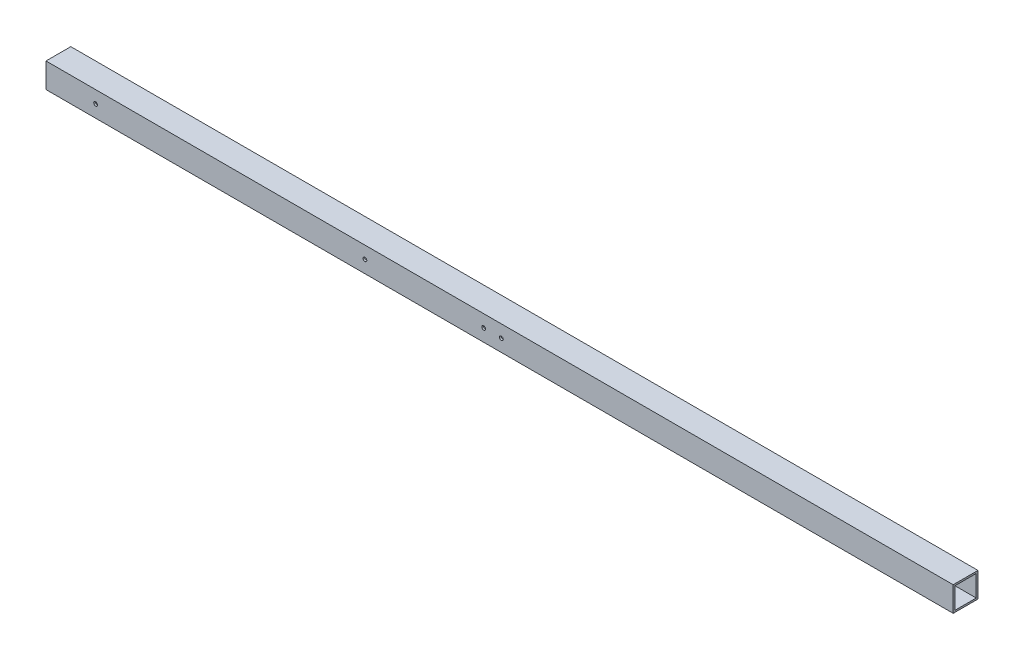
from build123d import *

# Parameters (mm, degrees)
SKETCH1_W           = 44.45
SKETCH1_H           = 44.45
SKETCH1_W_2         = 38.1
SKETCH1_H_2         = 38.1
BOSS_EXTRUDE1_DEPTH = 1625.6
SKETCH2_R           = 3.3734375
CUT_EXTRUDE1_DEPTH  = 45.45


with BuildPart() as part:
    # Sketch1 → Boss-Extrude1 (new body)
    with BuildSketch(Plane(origin=(0, 0, 0), x_dir=(0, 0, -1), z_dir=(1, 0, 0))):
        with Locations((22.225, 22.225)):
            Rectangle(SKETCH1_W, SKETCH1_H)
        with Locations((22.225, 22.225)):
            Rectangle(SKETCH1_W_2, SKETCH1_H_2, mode=Mode.SUBTRACT)
    extrude(amount=BOSS_EXTRUDE1_DEPTH)

    # Sketch2 → Cut-Extrude1 (cut, through all)
    with BuildSketch(Plane.XY):
        with Locations((784.225, 22.225)):
            Circle(SKETCH2_R)
        with Locations((815.975, 22.225)):
            Circle(SKETCH2_R)
        with Locations((571.5, 22.225)):
            Circle(SKETCH2_R)
        with Locations((88.9, 22.225)):
            Circle(SKETCH2_R)
    extrude(amount=-CUT_EXTRUDE1_DEPTH, mode=Mode.SUBTRACT)


solid = part.part
